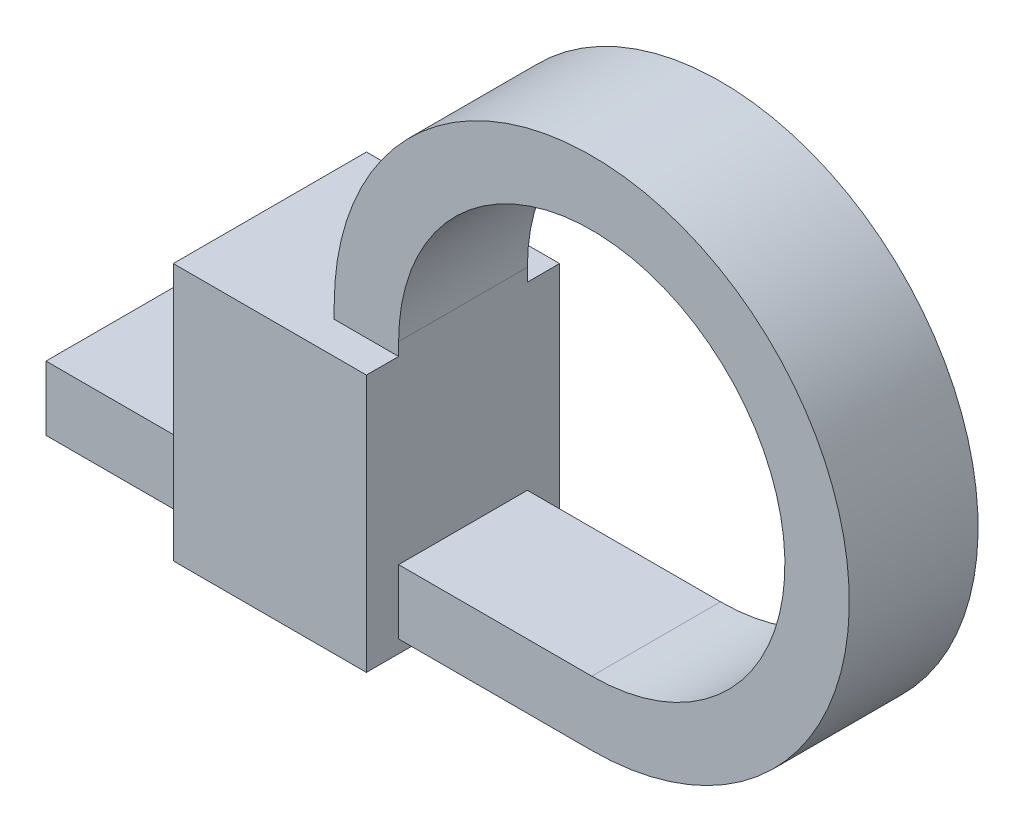
from build123d import *

# Parameters (mm, degrees)
SKETCH1_W           = 20
SKETCH1_H           = 20
EXTRUDE1_DEPTH      = 1
SKETCH2_W           = 20
SKETCH2_H           = 20
EXTRUDE2_DEPTH      = 1.5
EXTRUDE2_TAPER      = 75
SKETCH3_W           = 3
SKETCH3_H           = 4
EXTRUDE3_DEPTH      = 2
EXTRUDE_THIN1_DEPTH = 1.5
MOVE_FACE1_BY       = 1
MOVE_FACE1_2_BY     = 1
MOVE_FACE1_3_BY     = 1
SKETCH5_W           = 26.322025843
SKETCH5_H           = 24.141830142
CUT_EXTRUDE1_DEPTH  = 10


with BuildPart() as part:
    # Sketch1 → Extrude1 (new body)
    with BuildSketch(Plane(origin=(0, 0, 0), x_dir=(1, 0, 0), z_dir=(0, 1, 0))):
        Rectangle(SKETCH1_W, SKETCH1_H)
    extrude(amount=EXTRUDE1_DEPTH)

    # Sketch2 → Extrude2 (add)
    with BuildSketch(Plane(origin=(0, 1, 0), x_dir=(-1, 0, 0), z_dir=(0, 1, 0))):
        Rectangle(SKETCH2_W, SKETCH2_H)
    extrude(amount=EXTRUDE2_DEPTH, taper=EXTRUDE2_TAPER)

    # Sketch3 → Extrude3 (add, symmetric)
    with BuildSketch(Plane.XY):
        with Locations((-2.901923789, 4.5)):
            Rectangle(SKETCH3_W, SKETCH3_H)
    extrude(amount=EXTRUDE3_DEPTH, both=True)

    # Sketch4 → Extrude-Thin1 (add, symmetric)
    with BuildSketch(Plane.XY):
        with BuildLine():
            Line((-1.401923789, 6.5), (-1.401923789, 6.7))
            ThreePointArc((-1.401923789, 6.7), (3.719396555, 8.821320344), (1.598076211, 3.7))
            Line((1.598076211, 3.7), (-6.87859684, 3.7))
            Line((-6.87859684, 3.7), (-6.87859684, 2.7))
            Line((-6.87859684, 2.7), (1.598076211, 2.7))
            ThreePointArc((1.598076211, 2.7), (4.426503336, 9.528427125), (-2.401923789, 6.7))
            Line((-2.401923789, 6.7), (-2.401923789, 6.5))
            Line((-2.401923789, 6.5), (-1.401923789, 6.5))
        make_face()
    extrude(amount=EXTRUDE_THIN1_DEPTH, both=True)

    # Move Face1: a face moved inward by 1.0
    extrude(part.faces().sort_by_distance((-2.901923789, 4.5, 2))[0], amount=MOVE_FACE1_BY, dir=(0, 0, -1), mode=Mode.SUBTRACT)

    # Move Face1 2: a face moved inward by 1.0
    extrude(part.faces().sort_by_distance((1.598076211, 3.5, 1.5))[0], amount=MOVE_FACE1_2_BY, dir=(0, 0, -1), mode=Mode.SUBTRACT)

    # Move Face1 3: a face moved inward by 1.0
    extrude(part.faces().sort_by_distance((-5.640260314, 3.2, 1.5))[0], amount=MOVE_FACE1_3_BY, dir=(0, 0, -1), mode=Mode.SUBTRACT)

    # Sketch5 → Cut-Extrude1 (cut)
    with BuildSketch(Plane(origin=(0, 2.5, 0), x_dir=(1, 0, 0), z_dir=(0, 1, 0))):
        with Locations((0.290185678, -1.072850133)):
            Rectangle(SKETCH5_W, SKETCH5_H)
    extrude(amount=-CUT_EXTRUDE1_DEPTH, mode=Mode.SUBTRACT)


solid = part.part
